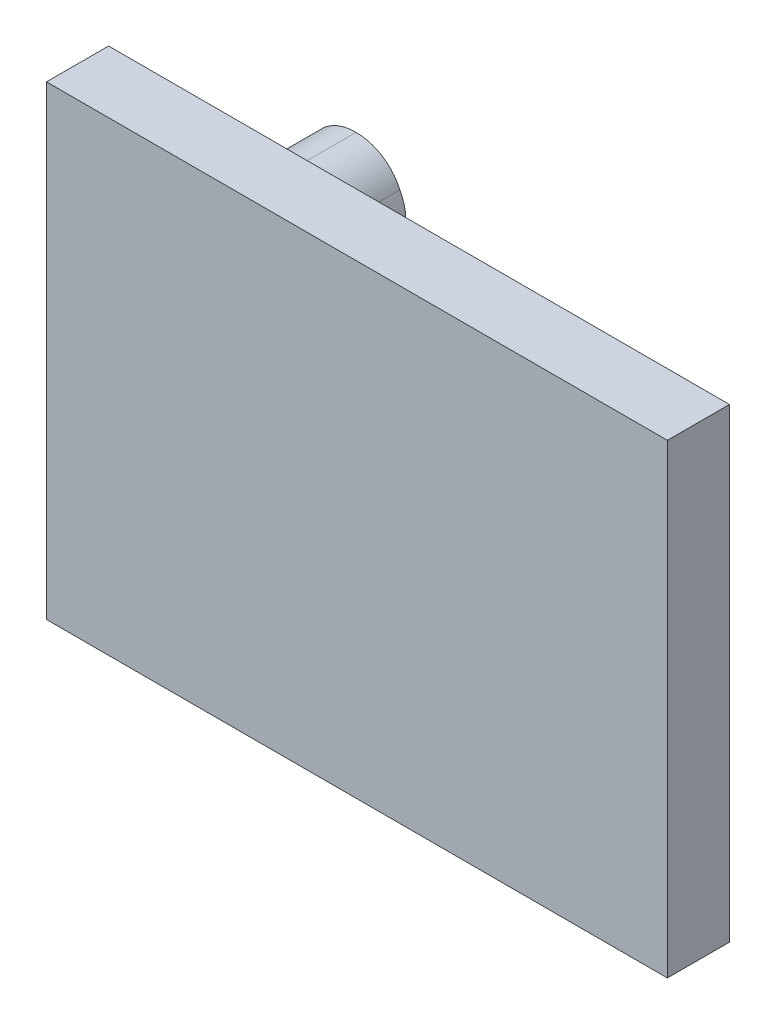
from build123d import *

# Parameters (mm, degrees)
SKETCH1_W           = 200
SKETCH1_H           = 150
BOSS_EXTRUDE1_DEPTH = 20
MIN_2_R             = 10.15
MIN_2_R_2           = 15.15
BOSS_EXTRUDE3_DEPTH = 30
MAX_LENTGH_R        = 10.15
MAX_LENTGH_R_2      = 15.15
BOSS_EXTRUDE4_DEPTH = 30
MAX_WIDTH_R         = 10.15
MAX_WIDTH_R_2       = 15.15
BOSS_EXTRUDE5_DEPTH = 30
MAX_2_R             = 10.15
MAX_2_R_2           = 15.15
BOSS_EXTRUDE6_DEPTH = 30


with BuildPart() as part:
    # Sketch1 → Boss-Extrude1 (new body)
    with BuildSketch(Plane.XY):
        Rectangle(SKETCH1_W, SKETCH1_H)
    extrude(amount=BOSS_EXTRUDE1_DEPTH)

    # min 2 → Boss-Extrude3 (add)
    with BuildSketch(Plane(origin=(0, 0, 0), x_dir=(-1, 0, 0), z_dir=(0, 0, -1))):
        with Locations((-50.3, -45.3)):
            Circle(MIN_2_R)
        with Locations((49.4, 44.4)):
            Circle(MIN_2_R_2)
    extrude(amount=BOSS_EXTRUDE3_DEPTH)

    # max - lentgh → Boss-Extrude4 (add)
    with BuildSketch(Plane(origin=(0, 0, 0), x_dir=(-1, 0, 0), z_dir=(0, 0, -1))):
        with Locations((-50, -44.7)):
            Circle(MAX_LENTGH_R)
        with Locations((50, 45.6)):
            Circle(MAX_LENTGH_R_2)
    extrude(amount=BOSS_EXTRUDE4_DEPTH)

    # max - width → Boss-Extrude5 (add)
    with BuildSketch(Plane(origin=(0, 0, 0), x_dir=(-1, 0, 0), z_dir=(0, 0, -1))):
        with Locations((-49.7, -45)):
            Circle(MAX_WIDTH_R)
        with Locations((50.6, 45)):
            Circle(MAX_WIDTH_R_2)
    extrude(amount=BOSS_EXTRUDE5_DEPTH)

    # max 2 → Boss-Extrude6 (add)
    with BuildSketch(Plane(origin=(0, 0, 0), x_dir=(-1, 0, 0), z_dir=(0, 0, -1))):
        with Locations((-49.7, -44.7)):
            Circle(MAX_2_R)
        with Locations((50.6, 45.6)):
            Circle(MAX_2_R_2)
    extrude(amount=BOSS_EXTRUDE6_DEPTH)


solid = part.part
